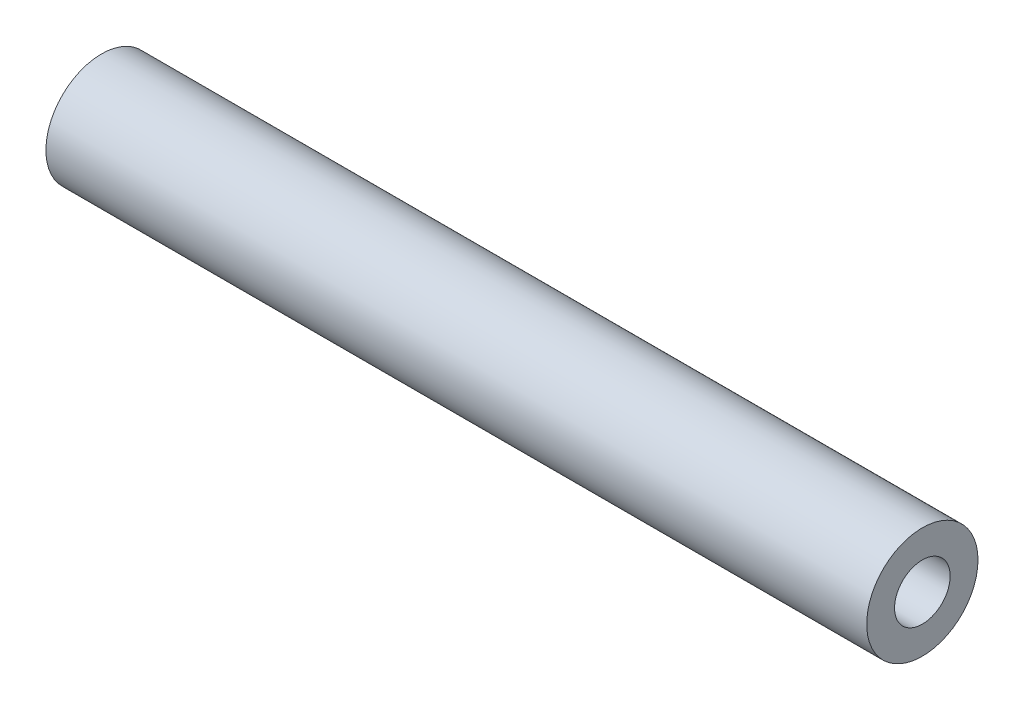
from build123d import *

# Parameters (mm, degrees)
SKETCH1_R           = 12.7
SKETCH1_R_2         = 6.35
BOSS_EXTRUDE1_DEPTH = 93.6625


with BuildPart() as part:
    # Sketch1 → Boss-Extrude1 (new body, symmetric)
    with BuildSketch(Plane(origin=(0, 0, 0), x_dir=(0, 0, -1), z_dir=(1, 0, 0))):
        Circle(SKETCH1_R)
        Circle(SKETCH1_R_2, mode=Mode.SUBTRACT)
    extrude(amount=BOSS_EXTRUDE1_DEPTH, both=True)


solid = part.part
